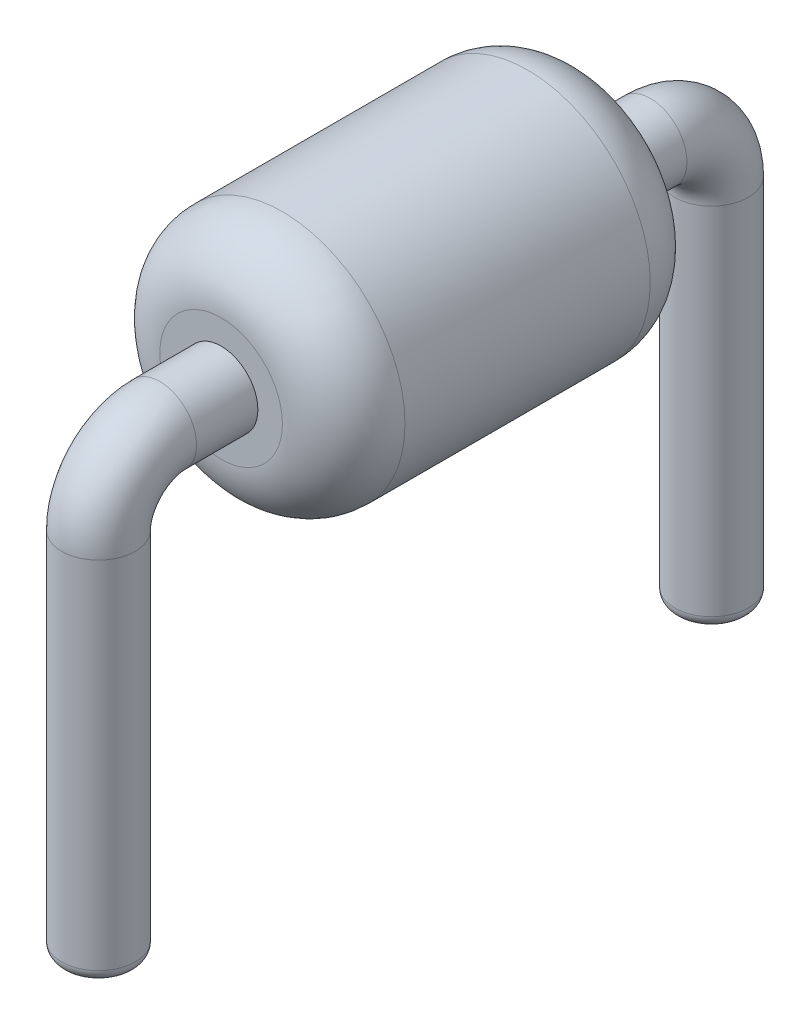
from build123d import *

# Parameters (mm, degrees)
SKETCH3_R           = 0.3
SKETCH4_R           = 1
SKETCH4_R_2         = 0.3
BOSS_EXTRUDE2_DEPTH = 3
FILLET1_R           = 0.5
FILLET2_R           = 0.1


with BuildPart() as part:
    # Sweep1: sweep along a path in Sketch2
    with BuildLine(Plane(origin=(0, 0, 0), x_dir=(0, 0, -1), z_dir=(1, 0, 0))) as sweep1_path:
        Line((0, 0), (0, 3))
        ThreePointArc((0, 3), (0.146446609, 3.353553391), (0.5, 3.5))
        Line((0.5, 3.5), (4.5, 3.5))
        ThreePointArc((4.5, 3.5), (4.853553391, 3.353553391), (5, 3))
        Line((5, 3), (5, 0))
    # Sketch3 → Sweep1 (sweep)
    with BuildSketch(Plane(origin=(0, 0, 0), x_dir=(1, 0, 0), z_dir=(0, 1, 0))):
        Circle(SKETCH3_R)
    sweep(path=sweep1_path.line)

    # Sketch4 → Boss-Extrude2 (add)
    with BuildSketch(Plane.XY.offset(-1)):
        with Locations((0, 3.5)):
            Circle(SKETCH4_R)
        with Locations((0, 3.5)):
            Circle(SKETCH4_R_2, mode=Mode.SUBTRACT)
    extrude(amount=-BOSS_EXTRUDE2_DEPTH)

    # Fillet1
    fillet1_edges = [part.edges().sort_by_distance(p)[0] for p in [
        (-1, 3.5, -4),
        (-1, 3.5, -1),
    ]]
    fillet(fillet1_edges, radius=FILLET1_R)

    # Fillet2
    fillet2_edges = [part.edges().sort_by_distance(p)[0] for p in [
        (-0.3, 0, 0),
        (-0.3, 0, -5),
    ]]
    fillet(fillet2_edges, radius=FILLET2_R)


solid = part.part
